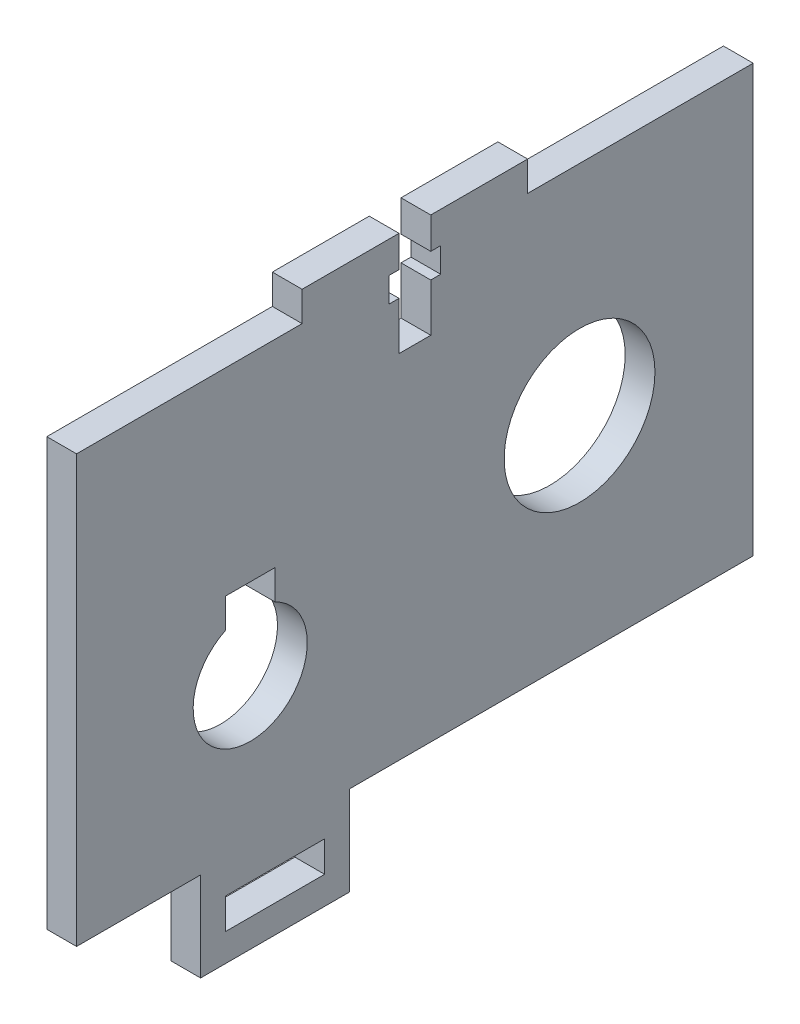
from build123d import *

# Parameters (mm, degrees)
SKETCH1_W               = 10
SKETCH1_H               = 3.1
SKETCH1_R               = 5.75
SKETCH1_R_2             = 7.6
BOSS_EXTRUDE1_DEPTH     = 3
CUT_EXTRUDE1_DEPTH      = 83.312749953
CUT_EXTRUDE1_DEPTH_BACK = 83.312749953


with BuildPart() as part:
    # Sketch1 → Boss-Extrude1 (new body)
    with BuildSketch(Plane(origin=(0, 0, 0), x_dir=(0, 0, -1), z_dir=(1, 0, 0))):
        Polygon((0, 43), (0, 0), (12.5, 0), (12.5, -9), (27.5, -9), (27.5, 0), (68.19375928, 0), (68.19375928, 43), (45.462506187, 43), (45.462506187, 46), (22.731253093, 46), (22.731253093, 43), align=None)
        with Locations((20, -4.65)):
            Rectangle(SKETCH1_W, SKETCH1_H, mode=Mode.SUBTRACT)
        with Locations((17.5, 14.8978)):
            Circle(SKETCH1_R, mode=Mode.SUBTRACT)
        with Locations((50.69375928, 21)):
            Circle(SKETCH1_R_2, mode=Mode.SUBTRACT)
    extrude(amount=BOSS_EXTRUDE1_DEPTH)

    # Sketch2 → Cut-Extrude1 (cut, two sides: drawn at the far end of the back side and taken through both)
    with BuildSketch(Plane(origin=(3, 0, 0), x_dir=(0, 0, -1), z_dir=(1, 0, 0)).offset(-CUT_EXTRUDE1_DEPTH_BACK)):
        with BuildLine():
            Line((15, 23.075878794), (15, 20.075878794))
            ThreePointArc((15, 20.075878794), (17.5, 20.6478), (20, 20.075878794))
            Line((20, 20.075878794), (20, 23.075878794))
            Line((20, 23.075878794), (15, 23.075878794))
        make_face()
        Polygon((31.49687964, 42.825), (31.49687964, 40.325), (32.49687964, 40.325), (32.49687964, 35.5), (35.69687964, 35.5), (35.69687964, 40.325), (36.69687964, 40.325), (36.69687964, 42.825), (35.69687964, 42.825), (35.69687964, 46), (32.49687964, 46), (32.49687964, 42.825), align=None)
    extrude(amount=CUT_EXTRUDE1_DEPTH + CUT_EXTRUDE1_DEPTH_BACK, mode=Mode.SUBTRACT)


solid = part.part
